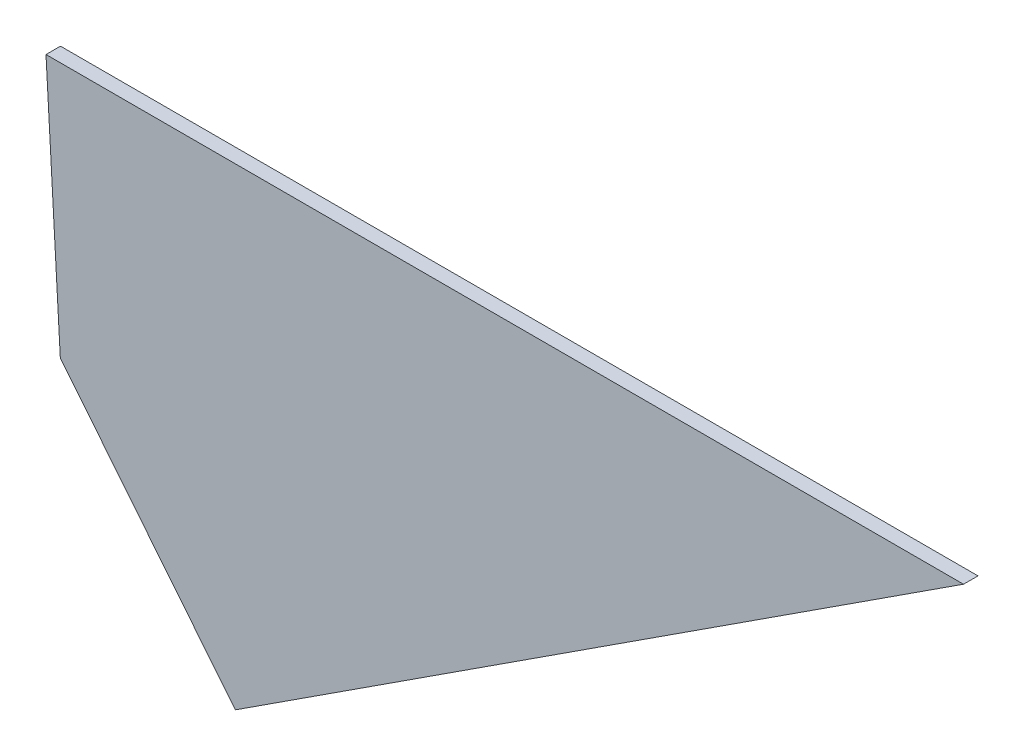
from build123d import *

# Parameters (mm, degrees)
BOSS_EXTRU_1_DEPTH = 3


with BuildPart() as part:
    # Esquisse1 → Boss.-Extru.1 (new body)
    with BuildSketch(Plane.XY):
        Polygon((58.687618568, -38.636327386), (-92.273083662, -136.671353689), (-125.32721644, -95.636327386), (-128.556325483, -91.627552586), (-131.522785253, -38.636327386), (-128.518088254, -38.636327386), align=None)
    extrude(amount=-BOSS_EXTRU_1_DEPTH)


solid = part.part
